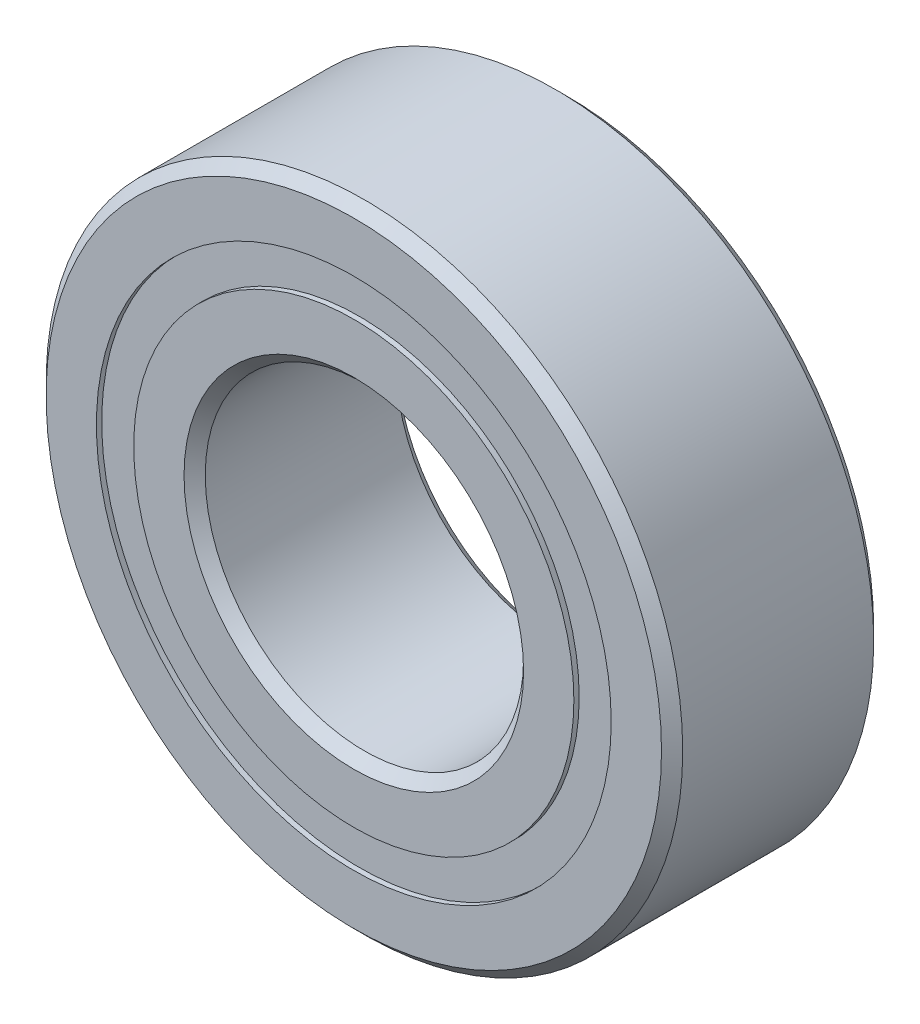
from build123d import *

# Parameters (mm, degrees)
CIRPATTERN1_COUNT = 12
SKETCH5_W         = 0.749364756
SKETCH5_H         = 0.558241758


with BuildPart() as part:
    # Sketch1 → Revolve1 (revolve)
    with BuildSketch(Plane(origin=(0, 0, 0), x_dir=(0, 0, -1), z_dir=(1, 0, 0))):
        with BuildLine():
            Line((1.42875, 4.7625), (-1.42875, 4.7625))
            Line((-1.42875, 4.7625), (-1.5875, 4.60375))
            Line((-1.5875, 4.60375), (-1.5875, 3.850995879))
            Line((-1.5875, 3.850995879), (-0.705555556, 3.850995879))
            ThreePointArc((-0.705555556, 3.850995879), (0, 4.330635244), (0.705555556, 3.850995879))
            Line((0.705555556, 3.850995879), (1.5875, 3.850995879))
            Line((1.5875, 3.850995879), (1.5875, 4.60375))
            Line((1.5875, 4.60375), (1.42875, 4.7625))
        make_face()
    revolve(axis=Axis((0, 0, 1.5875), (0, 0, -1)))


with BuildPart() as body_2:
    # Sketch3 → Revolve3 (revolve)
    with BuildSketch(Plane(origin=(0, 0, 0), x_dir=(0, 0, -1), z_dir=(1, 0, 0))):
        with BuildLine():
            Line((-0.705555556, 3.292754121), (-1.5875, 3.292754121))
            Line((-1.5875, 3.292754121), (-1.5875, 2.54))
            Line((-1.5875, 2.54), (-1.42875, 2.38125))
            Line((-1.42875, 2.38125), (1.42875, 2.38125))
            Line((1.42875, 2.38125), (1.5875, 2.54))
            Line((1.5875, 2.54), (1.5875, 3.292754121))
            Line((1.5875, 3.292754121), (0.705555556, 3.292754121))
            ThreePointArc((0.705555556, 3.292754121), (0, 2.813114756), (-0.705555556, 3.292754121))
        make_face()
    revolve(axis=Axis((0, 0, 1.5875), (0, 0, -1)))


with BuildPart() as body_3:
    # Sketch4 → Revolve4 (revolve)
    with BuildSketch(Plane(origin=(0, 0, 0), x_dir=(0, 0, -1), z_dir=(1, 0, 0))):
        with BuildLine():
            Line((-0.758760244, 3.571875), (0.758760244, 3.571875))
            ThreePointArc((0.758760244, 3.571875), (0, 4.330635244), (-0.758760244, 3.571875))
        make_face()
    revolve(axis=Axis((0, 3.571875, 0.758760244), (0, 0, -1)))


with BuildPart() as cirpattern1_1:
    # CirPattern1: pattern copy
    add(body_3.part.rotate(Axis((0, 0, 0), (0, 0, 1)), 1 * 360 / CIRPATTERN1_COUNT))


with BuildPart() as cirpattern1_2:
    # CirPattern1: pattern copy
    add(body_3.part.rotate(Axis((0, 0, 0), (0, 0, 1)), 2 * 360 / CIRPATTERN1_COUNT))


with BuildPart() as cirpattern1_3:
    # CirPattern1: pattern copy
    add(body_3.part.rotate(Axis((0, 0, 0), (0, 0, 1)), 3 * 360 / CIRPATTERN1_COUNT))


with BuildPart() as cirpattern1_4:
    # CirPattern1: pattern copy
    add(body_3.part.rotate(Axis((0, 0, 0), (0, 0, 1)), 4 * 360 / CIRPATTERN1_COUNT))


with BuildPart() as cirpattern1_5:
    # CirPattern1: pattern copy
    add(body_3.part.rotate(Axis((0, 0, 0), (0, 0, 1)), 5 * 360 / CIRPATTERN1_COUNT))


with BuildPart() as cirpattern1_6:
    # CirPattern1: pattern copy
    add(body_3.part.rotate(Axis((0, 0, 0), (0, 0, 1)), 6 * 360 / CIRPATTERN1_COUNT))


with BuildPart() as cirpattern1_7:
    # CirPattern1: pattern copy
    add(body_3.part.rotate(Axis((0, 0, 0), (0, 0, 1)), 7 * 360 / CIRPATTERN1_COUNT))


with BuildPart() as cirpattern1_8:
    # CirPattern1: pattern copy
    add(body_3.part.rotate(Axis((0, 0, 0), (0, 0, 1)), 8 * 360 / CIRPATTERN1_COUNT))


with BuildPart() as cirpattern1_9:
    # CirPattern1: pattern copy
    add(body_3.part.rotate(Axis((0, 0, 0), (0, 0, 1)), 9 * 360 / CIRPATTERN1_COUNT))


with BuildPart() as cirpattern1_10:
    # CirPattern1: pattern copy
    add(body_3.part.rotate(Axis((0, 0, 0), (0, 0, 1)), 10 * 360 / CIRPATTERN1_COUNT))


with BuildPart() as cirpattern1_11:
    # CirPattern1: pattern copy
    add(body_3.part.rotate(Axis((0, 0, 0), (0, 0, 1)), 11 * 360 / CIRPATTERN1_COUNT))


with BuildPart() as body_15:
    # Sketch5 → Revolve5 (revolve)
    with BuildSketch(Plane(origin=(0, 0, 0), x_dir=(0, 0, -1), z_dir=(1, 0, 0))):
        with Locations((-1.133442622, 3.571875)):
            Rectangle(SKETCH5_W, SKETCH5_H)
        with Locations((1.133442622, 3.571875)):
            Rectangle(SKETCH5_W, SKETCH5_H)
    revolve(axis=Axis((0, 0, 1.5875), (0, 0, -1)))


solid = Compound([part.part, body_2.part, body_3.part, cirpattern1_1.part, cirpattern1_2.part, cirpattern1_3.part, cirpattern1_4.part, cirpattern1_5.part, cirpattern1_6.part, cirpattern1_7.part, cirpattern1_8.part, cirpattern1_9.part, cirpattern1_10.part, cirpattern1_11.part, body_15.part])
